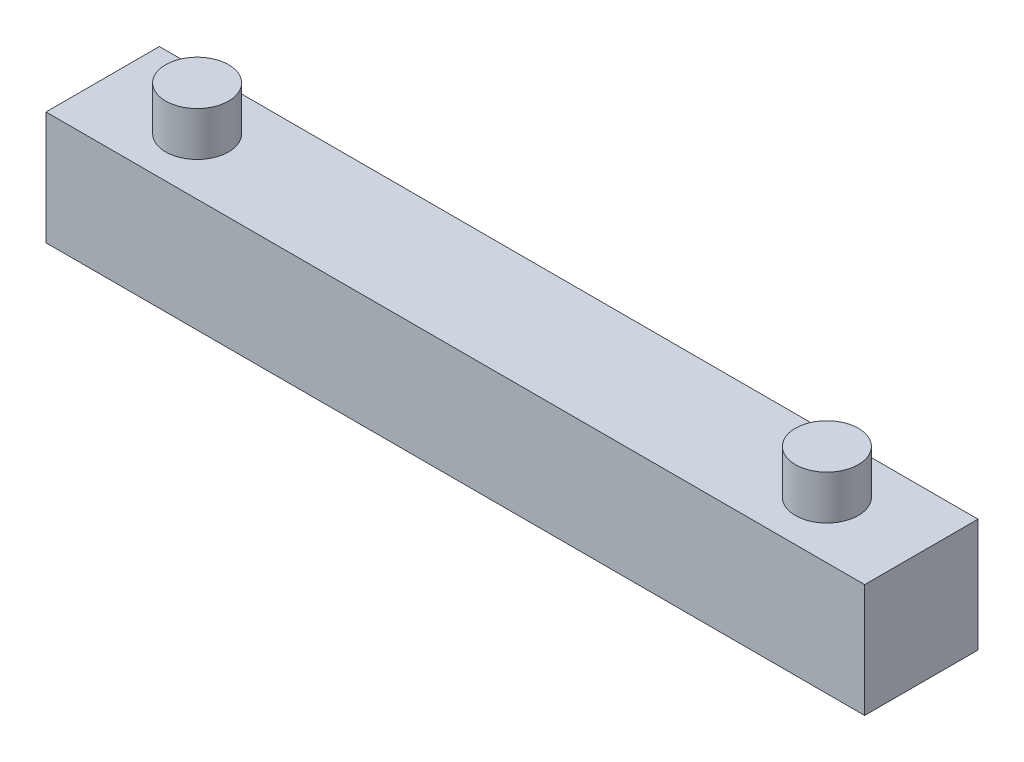
from build123d import *

# Parameters (mm, degrees)
SKETCH1_W           = 65
SKETCH1_H           = 9
BOSS_EXTRUDE1_DEPTH = 9
SKETCH2_R           = 2.5
BOSS_EXTRUDE2_DEPTH = 3.5


with BuildPart() as part:
    # Sketch1 → Boss-Extrude1 (new body)
    with BuildSketch(Plane(origin=(0, 0, 0), x_dir=(1, 0, 0), z_dir=(0, 1, 0))):
        Rectangle(SKETCH1_W, SKETCH1_H)
    extrude(amount=BOSS_EXTRUDE1_DEPTH)

    # Sketch2 → Boss-Extrude2 (add)
    with BuildSketch(Plane(origin=(0, 9, 0), x_dir=(1, 0, 0), z_dir=(0, 1, 0))):
        with Locations((-25, 0)):
            Circle(SKETCH2_R)
        with Locations((25, 0)):
            Circle(SKETCH2_R)
    extrude(amount=BOSS_EXTRUDE2_DEPTH)


solid = part.part
